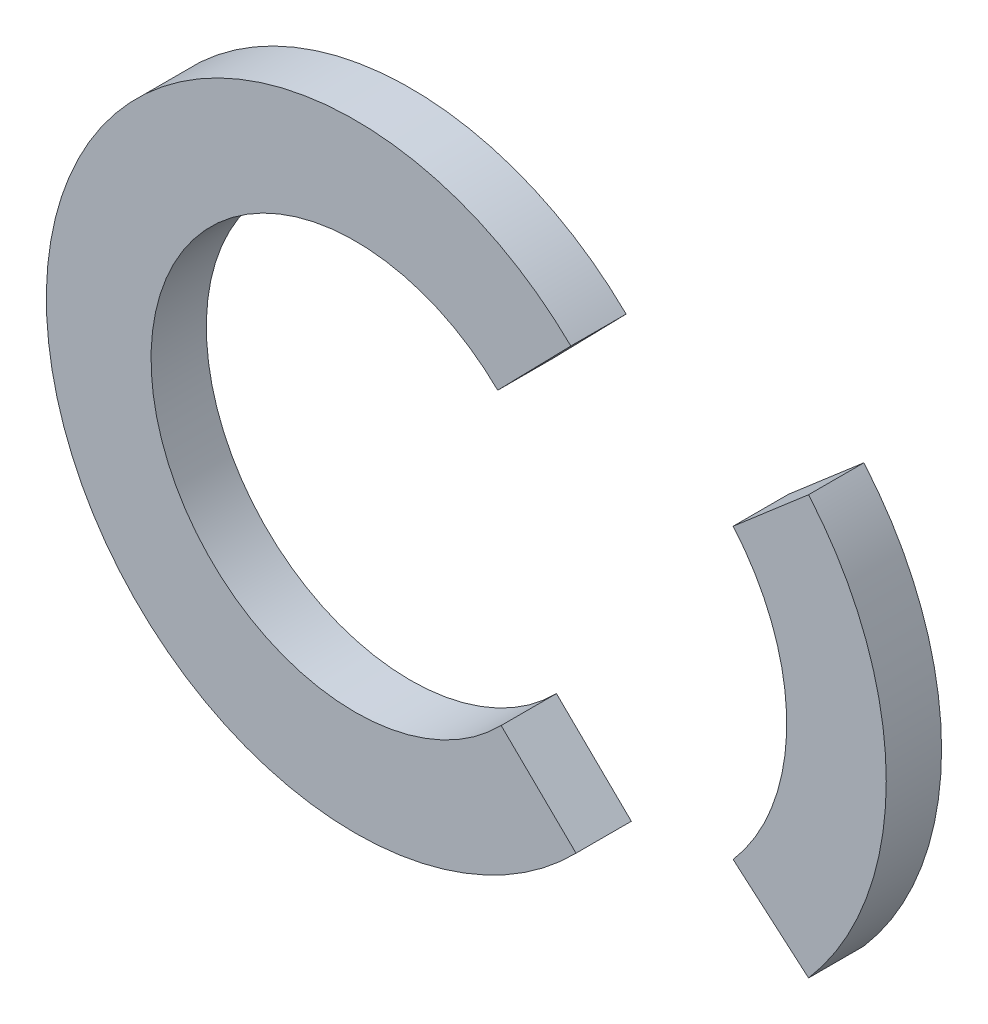
from build123d import *

# Parameters (mm, degrees)
BOSS_EXTRU_1_DEPTH   = 10
BOSS_EXTRU_1_2_DEPTH = 10


with BuildPart() as part:
    # Esquisse1 → Boss.-Extru.1 (new body)
    with BuildSketch(Plane.XY):
        with BuildLine():
            Line((39.01615362, 39.95435827), (25.788949124, 26.409084882))
            ThreePointArc((25.788949124, 26.409084882), (-36.90958381, -0.438502199), (26.409084882, -25.788949124))
            Line((26.409084882, -25.788949124), (39.95435827, -39.01615362))
            ThreePointArc((39.95435827, -39.01615362), (-55.840584471, -0.66341087), (39.01615362, 39.95435827))
        make_face()
    extrude(amount=BOSS_EXTRU_1_DEPTH)


with BuildPart() as body_2:
    # Esquisse1 → Boss.-Extru.1 2 (new body)
    with BuildSketch(Plane.XY):
        with BuildLine():
            Line((82.008015058, 38.158396684), (68.371531927, 26.409084882))
            ThreePointArc((68.371531927, 26.409084882), (78.064312482, 0.310067879), (68.371531927, -25.788949124))
            Line((68.371531927, -25.788949124), (82.008015058, -37.538260927))
            ThreePointArc((82.008015058, -37.538260927), (96.064312482, 0.310067879), (82.008015058, 38.158396684))
        make_face()
    extrude(amount=BOSS_EXTRU_1_2_DEPTH)


solid = Compound([part.part, body_2.part])
